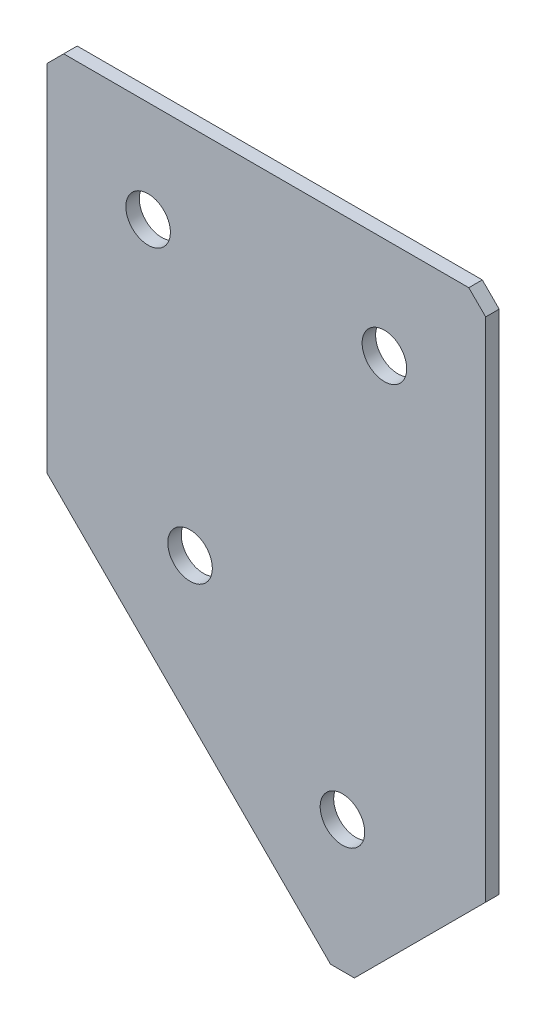
from build123d import *

# Parameters (mm, degrees)
EXTRUDE_1_DEPTH   = 2
HOLE_WIZARD_M61_D = 6.6
CHAMFER_1_SIZE    = 2.5


with BuildPart() as part:
    # Эскиз3 → Бобышка-Вытянуть1 (new body)
    with BuildSketch(Plane(origin=(0, 0, 0), x_dir=(1, 0, 0), z_dir=(0, 0, -1))):
        Polygon((0, 0), (65, 0), (65, 77.573593129), (43.786796564, 98.786796564), (0, 55), align=None)
    extrude(amount=EXTRUDE_1_DEPTH)

    # Отверстие с зазором M61 (through all)
    with Locations(Plane(origin=(0, 0, -2), x_dir=(1, 0, 0), z_dir=(0, 0, -1))):
        with Locations((15, 15), (50, 15), (21.213203436, 55), (43.786796564, 77.573593129)):
            Hole(HOLE_WIZARD_M61_D / 2)

    # Фаска1
    chamfer_1_edges = [part.edges().sort_by_distance(p)[0] for p in [
        (43.786796564, -98.786796564, -1),
        (65, 0, -1),
        (0, 0, -1),
    ]]
    chamfer(chamfer_1_edges, length=CHAMFER_1_SIZE)


solid = part.part
